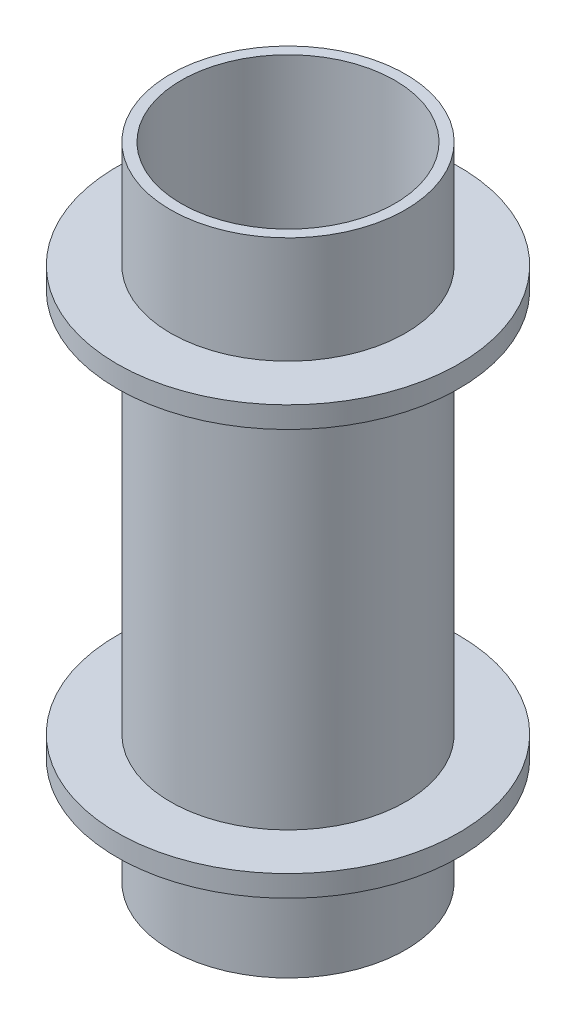
from build123d import *

# Parameters (mm, degrees)
SKETCH_1_R      = 11
SKETCH_1_R_2    = 10
EXTRUDE_1_DEPTH = 60
EXTRUDE_START   = -10
SKETCH_2_R      = 16
SKETCH_2_R_2    = 11
EXTRUDE_3_DEPTH = 2
SKETCH_3_R      = 16
SKETCH_3_R_2    = 11
EXTRUDE_4_DEPTH = 2


with BuildPart() as part:
    # Эскиз1 → Бобышка-Вытянуть1 (new body)
    with BuildSketch(Plane(origin=(0, 0, 0), x_dir=(1, 0, 0), z_dir=(0, 1, 0))):
        Circle(SKETCH_1_R)
        Circle(SKETCH_1_R_2, mode=Mode.SUBTRACT)
    extrude(amount=EXTRUDE_1_DEPTH)

    # Эскиз2 → Бобышка-Вытянуть3 (add)
    with BuildSketch(Plane(origin=(0, 60, 0), x_dir=(1, 0, 0), z_dir=(0, 1, 0)).offset(EXTRUDE_START)):
        Circle(SKETCH_2_R)
        Circle(SKETCH_2_R_2, mode=Mode.SUBTRACT)
    extrude(amount=-EXTRUDE_3_DEPTH)

    # Эскиз3 → Бобышка-Вытянуть4 (add)
    with BuildSketch(Plane.XZ.offset(EXTRUDE_START)):
        Circle(SKETCH_3_R)
        Circle(SKETCH_3_R_2, mode=Mode.SUBTRACT)
    extrude(amount=-EXTRUDE_4_DEPTH)


solid = part.part
